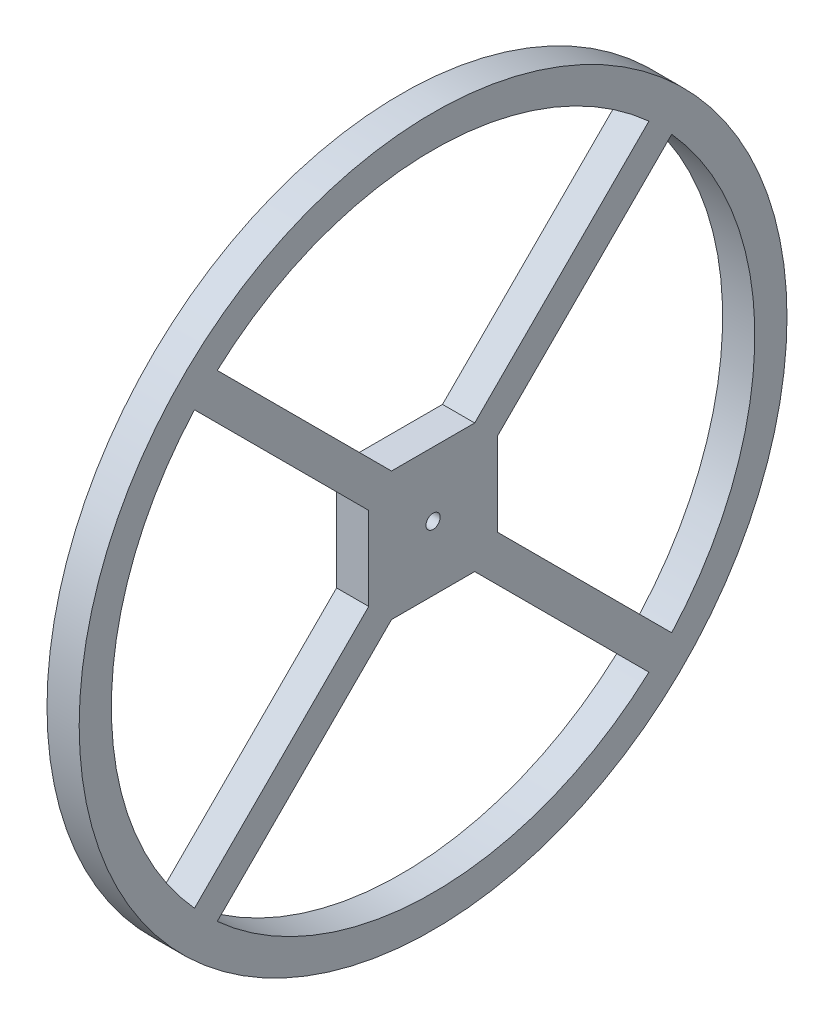
from build123d import *

# Parameters (mm, degrees)
SKETCH1_R           = 55
BOSS_EXTRUDE1_DEPTH = 5
SKETCH2_W           = 15.3
SKETCH2_H           = 15.3
SKETCH2_R           = 1.1
BOSS_EXTRUDE2_DEPTH = 2


with BuildPart() as part:
    # Sketch1 → Boss-Extrude1 (new body)
    with BuildSketch(Plane(origin=(0, 0, 0), x_dir=(0, 0, -1), z_dir=(1, 0, 0))):
        Circle(SKETCH1_R)
        with BuildLine():
            Line((-33.543350277, -37.078884183), (-6.464466094, -10))
            Line((-6.464466094, -10), (6.464466094, -10))
            Line((6.464466094, -10), (33.543350277, -37.078884183))
            ThreePointArc((33.543350277, -37.078884183), (0, -50), (-33.543350277, -37.078884183))
        make_face(mode=Mode.SUBTRACT)
        with BuildLine():
            Line((10, -6.464466094), (10, 6.464466094))
            Line((10, 6.464466094), (37.078884183, 33.543350277))
            ThreePointArc((37.078884183, 33.543350277), (50, 0), (37.078884183, -33.543350277))
            Line((37.078884183, -33.543350277), (10, -6.464466094))
        make_face(mode=Mode.SUBTRACT)
        with BuildLine():
            Line((-37.078884183, 33.543350277), (-10, 6.464466094))
            Line((-10, 6.464466094), (-10, -6.464466094))
            Line((-10, -6.464466094), (-37.078884183, -33.543350277))
            ThreePointArc((-37.078884183, -33.543350277), (-50, 0), (-37.078884183, 33.543350277))
        make_face(mode=Mode.SUBTRACT)
        with BuildLine():
            Line((-0.616796039, -3.445223164), (-4.821572875, -7.65))
            Line((-4.821572875, -7.65), (-7.65, -7.65))
            Line((-7.65, -7.65), (-7.65, -4.821572875))
            Line((-7.65, -4.821572875), (-3.445223164, -0.616796039))
            ThreePointArc((-3.445223164, -0.616796039), (-3.5, 0), (-3.445223164, 0.616796039))
            Line((-3.445223164, 0.616796039), (-7.65, 4.821572875))
            Line((-7.65, 4.821572875), (-7.65, 7.65))
            Line((-7.65, 7.65), (-4.821572875, 7.65))
            Line((-4.821572875, 7.65), (-0.616796039, 3.445223164))
            ThreePointArc((-0.616796039, 3.445223164), (0, 3.5), (0.616796039, 3.445223164))
            Line((0.616796039, 3.445223164), (4.821572875, 7.65))
            Line((4.821572875, 7.65), (7.65, 7.65))
            Line((7.65, 7.65), (7.65, 4.821572875))
            Line((7.65, 4.821572875), (3.445223164, 0.616796039))
            ThreePointArc((3.445223164, 0.616796039), (3.5, 0), (3.445223164, -0.616796039))
            Line((3.445223164, -0.616796039), (7.65, -4.821572875))
            Line((7.65, -4.821572875), (7.65, -7.65))
            Line((7.65, -7.65), (4.821572875, -7.65))
            Line((4.821572875, -7.65), (0.616796039, -3.445223164))
            ThreePointArc((0.616796039, -3.445223164), (0, -3.5), (-0.616796039, -3.445223164))
        make_face(mode=Mode.SUBTRACT)
        with BuildLine():
            Line((6.464466094, 10), (-6.464466094, 10))
            Line((-6.464466094, 10), (-33.543350277, 37.078884183))
            ThreePointArc((-33.543350277, 37.078884183), (0, 50), (33.543350277, 37.078884183))
            Line((33.543350277, 37.078884183), (6.464466094, 10))
        make_face(mode=Mode.SUBTRACT)
    extrude(amount=BOSS_EXTRUDE1_DEPTH)

    # Sketch2 → Boss-Extrude2 (add)
    with BuildSketch(Plane(origin=(5, 0, 0), x_dir=(0, 0, -1), z_dir=(1, 0, 0))):
        Rectangle(SKETCH2_W, SKETCH2_H)
        Circle(SKETCH2_R, mode=Mode.SUBTRACT)
    extrude(amount=-BOSS_EXTRUDE2_DEPTH)


solid = part.part
